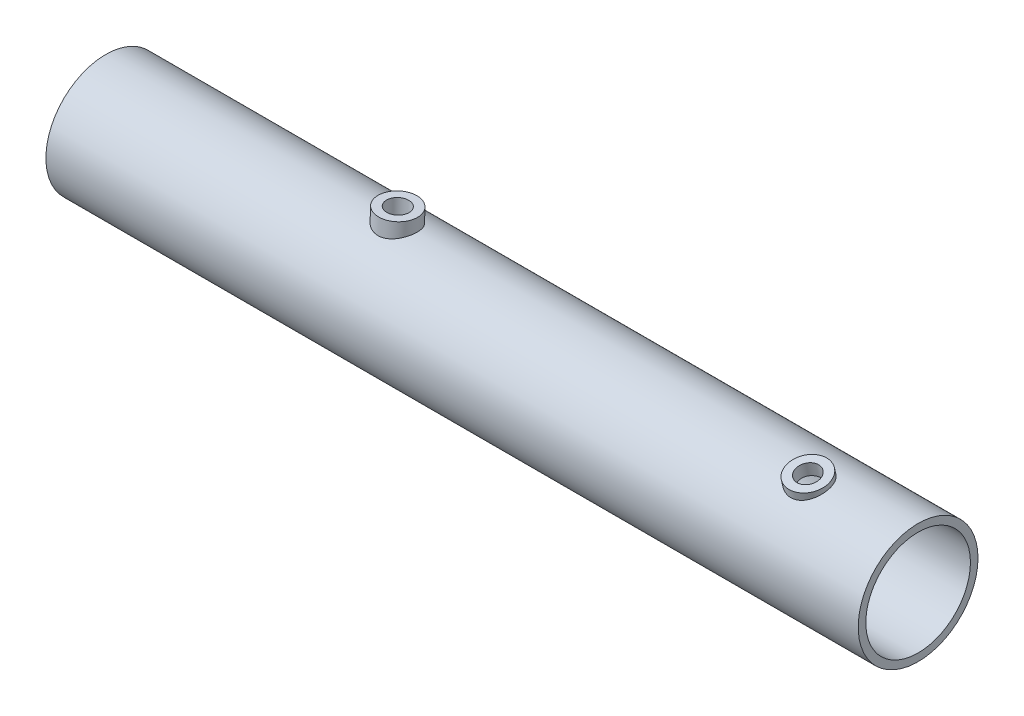
from build123d import *

# Parameters (mm, degrees)
SKETCH1_R           = 21.75
SKETCH1_R_2         = 19
BOSS_EXTRUDE1_DEPTH = 295
BOSS_EXTRUDE2_REACH = 51.786
SKETCH5_R           = 7
SKETCH5_R_2         = 4
BOSS_EXTRUDE3_REACH = 51.455
SKETCH6_R           = 7
SKETCH6_R_2         = 4
SKETCH7_R           = 4
CUT_EXTRUDE1_DEPTH  = 10
SKETCH8_R           = 4
CUT_EXTRUDE2_DEPTH  = 20


with BuildPart() as part:
    # Sketch1 → Boss-Extrude1 (new body)
    with BuildSketch(Plane(origin=(0, 0, 0), x_dir=(0, 0, -1), z_dir=(1, 0, 0))):
        Circle(SKETCH1_R)
        Circle(SKETCH1_R_2, mode=Mode.SUBTRACT)
    extrude(amount=BOSS_EXTRUDE1_DEPTH)

    # Sketch5 → Boss-Extrude2 (add, up to next)
    with BuildSketch(Plane(origin=(0.022625841, 23.166571161, 5.264124015), x_dir=(0.999999546, -0.000927561, -0.00021607), z_dir=(-0.000952381, -0.975141562, -0.221580746)), mode=Mode.PRIVATE) as boss_extrude2_sk1:
        with Locations((260.436740743, 0.291462923)):
            Circle(SKETCH5_R)
        with Locations((260.436740743, 0.291462923)):
            Circle(SKETCH5_R_2, mode=Mode.SUBTRACT)
    boss_extrude2_tool1 = extrude(boss_extrude2_sk1.sketch, amount=BOSS_EXTRUDE2_REACH, mode=Mode.PRIVATE) - part.part
    add(boss_extrude2_tool1.solids().sort_by_distance((253.657243, 22.866727, 5.493539))[0])

    # Sketch6 → Boss-Extrude3 (add, up to next)
    with BuildSketch(Plane(origin=(0.192055035, 27.157330053, -0.682085947), x_dir=(0.999975011, -0.007067306, 0.000177503), z_dir=(-0.007069535, -0.999659759, 0.025107545)), mode=Mode.PRIVATE) as boss_extrude3_sk1:
        with Locations((105.278439441, 0.08752168)):
            Circle(SKETCH6_R)
        with Locations((105.278439441, 0.08752168)):
            Circle(SKETCH6_R_2, mode=Mode.SUBTRACT)
    boss_extrude3_tool1 = extrude(boss_extrude3_sk1.sketch, amount=BOSS_EXTRUDE3_REACH, mode=Mode.PRIVATE) - part.part
    add(boss_extrude3_tool1.solids().sort_by_distance((98.666024, 26.463564, -0.577112))[0])

    # Sketch7 → Cut-Extrude1 (cut)
    with BuildSketch(Plane(origin=(0.022625841, 23.166571161, 5.264124015), x_dir=(0.999999546, -0.000927561, -0.00021607), z_dir=(0.000952381, 0.975141562, 0.221580746))):
        with Locations((260.436740743, -0.291462923)):
            Circle(SKETCH7_R)
    extrude(amount=-CUT_EXTRUDE1_DEPTH, mode=Mode.SUBTRACT)

    # Sketch8 → Cut-Extrude2 (cut)
    with BuildSketch(Plane(origin=(0.192055035, 27.157330053, -0.682085947), x_dir=(0.999975011, -0.007067306, 0.000177503), z_dir=(0.007069535, 0.999659759, -0.025107545))):
        with Locations((105.278439441, -0.08752168)):
            Circle(SKETCH8_R)
    extrude(amount=-CUT_EXTRUDE2_DEPTH, mode=Mode.SUBTRACT)


solid = part.part
